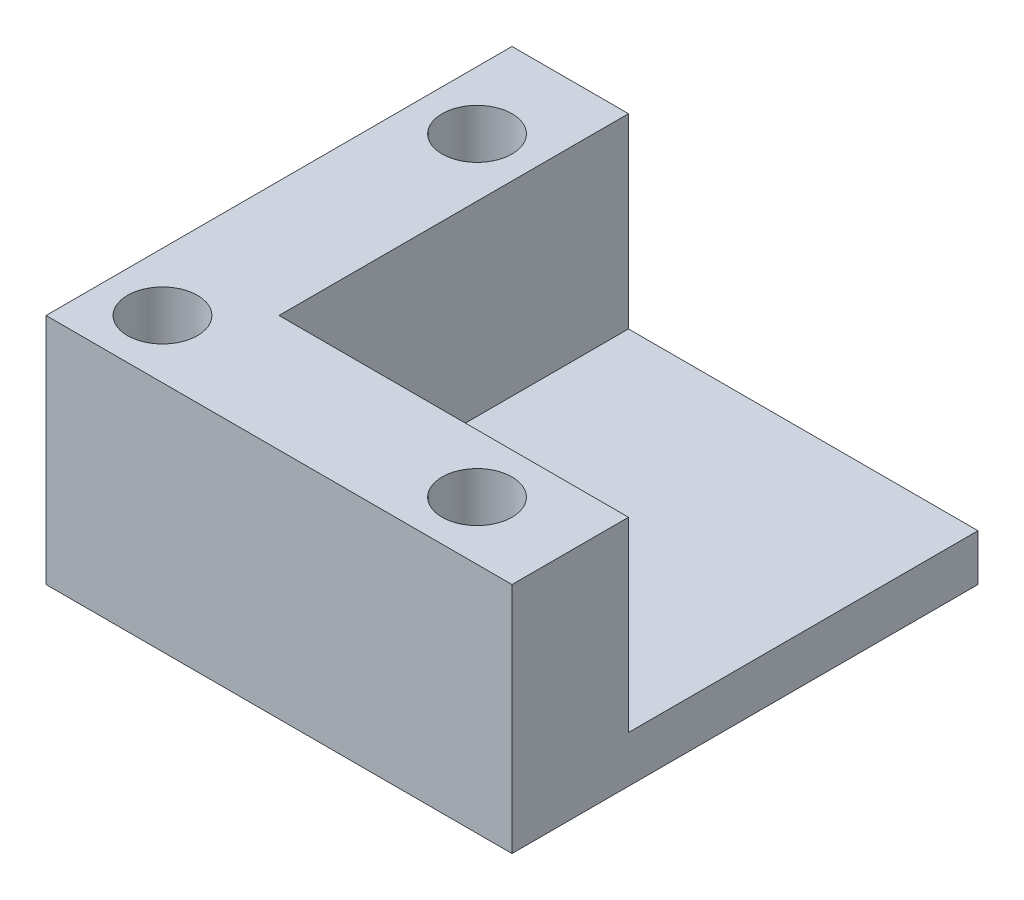
from build123d import *

# Parameters (mm, degrees)
SKETCH1_W           = 25.4
SKETCH1_H           = 25.4
BOSS_EXTRUDE1_DEPTH = 2.54
BOSS_EXTRUDE2_DEPTH = 10.16
SKETCH3_R           = 1.905
CUT_EXTRUDE1_DEPTH  = 6.35


with BuildPart() as part:
    # Sketch1 → Boss-Extrude1 (new body)
    with BuildSketch(Plane(origin=(0, 0, 0), x_dir=(1, 0, 0), z_dir=(0, 1, 0))):
        with Locations((12.7, 12.7)):
            Rectangle(SKETCH1_W, SKETCH1_H)
    extrude(amount=BOSS_EXTRUDE1_DEPTH)

    # Sketch2 → Boss-Extrude2 (add)
    with BuildSketch(Plane(origin=(0, 2.54, 0), x_dir=(1, 0, 0), z_dir=(0, 1, 0))):
        Polygon((0, 25.4), (0, 0), (25.4, 0), (25.4, 6.35), (6.35, 6.35), (6.35, 25.4), align=None)
    extrude(amount=BOSS_EXTRUDE2_DEPTH)

    # Sketch3 → Cut-Extrude1 (cut)
    with BuildSketch(Plane(origin=(0, 12.7, 0), x_dir=(1, 0, 0), z_dir=(0, 1, 0))):
        with Locations((3.175, 20.32)):
            Circle(SKETCH3_R)
        with Locations((3.175, 3.175)):
            Circle(SKETCH3_R)
        with Locations((20.32, 3.175)):
            Circle(SKETCH3_R)
    extrude(amount=-CUT_EXTRUDE1_DEPTH, mode=Mode.SUBTRACT)


solid = part.part
